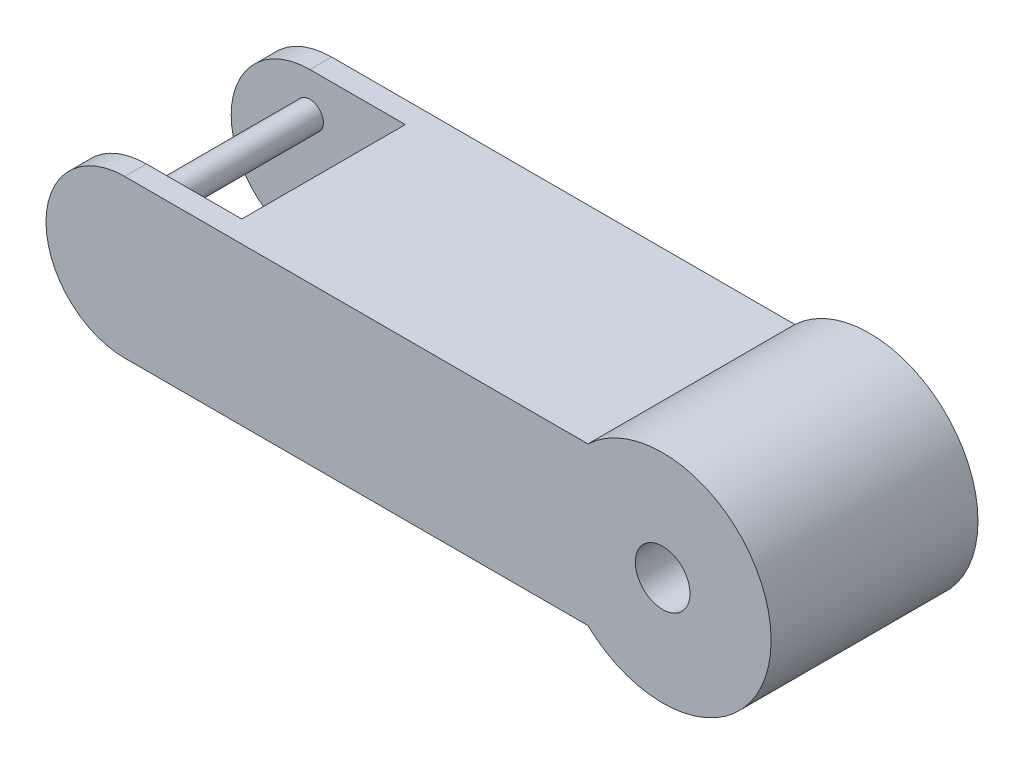
from build123d import *

# Parameters (mm, degrees)
SKETCH1_R                = 20
SKETCH1_R_2              = 14.505051228
BOSS_EXTRUDE1_DEPTH      = 4
BOSS_EXTRUDE2_DEPTH      = 15.075
SKETCH3_R                = 5.05
CUT_EXTRUDE1_DEPTH       = 51.075
SKETCH4_R                = 2.5
BOSS_EXTRUDE3_DEPTH      = 32
BOSS_EXTRUDE3_DEPTH_BACK = 2


with BuildPart() as part:
    # Sketch1 → Boss-Extrude1 (new body)
    with BuildSketch(Plane.XY):
        Circle(SKETCH1_R)
        with BuildLine():
            Line((-99.203276416, -14.505051228), (-13.76965827, -14.505051228))
            ThreePointArc((-13.76965827, -14.505051228), (-20, 0), (-13.76965827, 14.505051228))
            Line((-13.76965827, 14.505051228), (-99.203276416, 14.505051228))
            ThreePointArc((-99.203276416, 14.505051228), (-88.946656331, 10.256620085), (-84.698225188, 0))
            ThreePointArc((-84.698225188, 0), (-88.946656331, -10.256620085), (-99.203276416, -14.505051228))
        make_face()
        with Locations((-99.203276416, 0)):
            Circle(SKETCH1_R_2)
    extrude(amount=BOSS_EXTRUDE1_DEPTH)

    # Sketch2 → Boss-Extrude2 (add)
    with BuildSketch(Plane.XY.offset(4)):
        with BuildLine():
            Line((-13.76965827, 14.505051228), (-81.604060492, 14.505051228))
            ThreePointArc((-81.604060492, 14.505051228), (-67.970381175, 0), (-81.604060492, -14.505051228))
            Line((-81.604060492, -14.505051228), (-13.76965827, -14.505051228))
            ThreePointArc((-13.76965827, -14.505051228), (20, 0), (-13.76965827, 14.505051228))
        make_face()
    extrude(amount=BOSS_EXTRUDE2_DEPTH)

    # Mirror1: part across plane


with BuildPart() as part_1:
    add(part.part)
    add(part.part.mirror(Plane.XY.offset(19.075)))

    # Sketch3 → Cut-Extrude1 (cut)
    with BuildSketch(Plane(origin=(0, 0, 0), x_dir=(-1, 0, 0), z_dir=(0, 0, -1))):
        Circle(SKETCH3_R)
    extrude(amount=-CUT_EXTRUDE1_DEPTH, mode=Mode.SUBTRACT)

    # Sketch4 → Boss-Extrude3 (add, two sides)
    with BuildSketch(Plane(origin=(0, 0, 34.15), x_dir=(-1, 0, 0), z_dir=(0, 0, -1))) as boss_extrude3_sk:
        with Locations((99.203276416, 7.252525614)):
            Circle(SKETCH4_R)
        with Locations((99.203276416, -7.252525614)):
            Circle(SKETCH4_R)
    extrude(amount=BOSS_EXTRUDE3_DEPTH)
    extrude(boss_extrude3_sk.sketch, amount=-BOSS_EXTRUDE3_DEPTH_BACK)


solid = part_1.part
